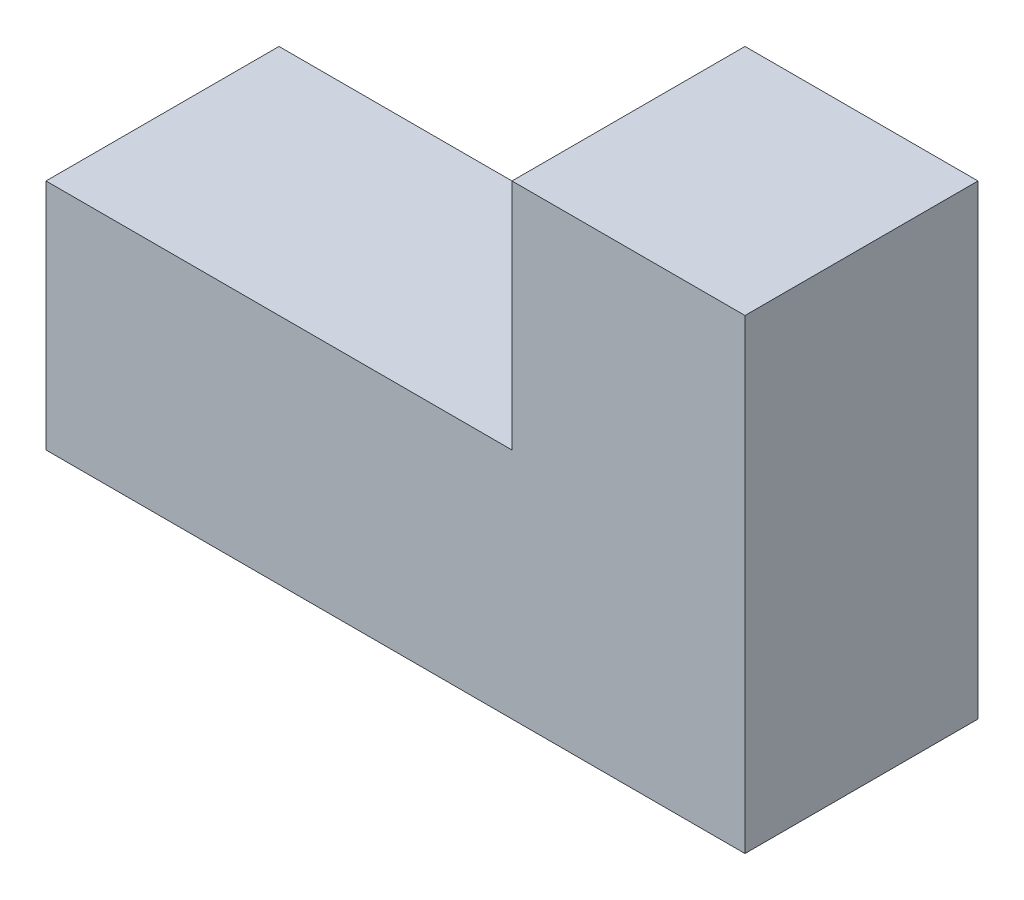
from build123d import *

# Parameters (mm, degrees)
BOSS_EXTRUDE1_DEPTH = 30


with BuildPart() as part:
    # Sketch1 → Boss-Extrude1 (new body)
    with BuildSketch(Plane.XY):
        Polygon((-75, 0), (15, 0), (15, 60), (-15, 60), (-15, 30), (-75, 30), align=None)
    extrude(amount=-BOSS_EXTRUDE1_DEPTH)


solid = part.part
